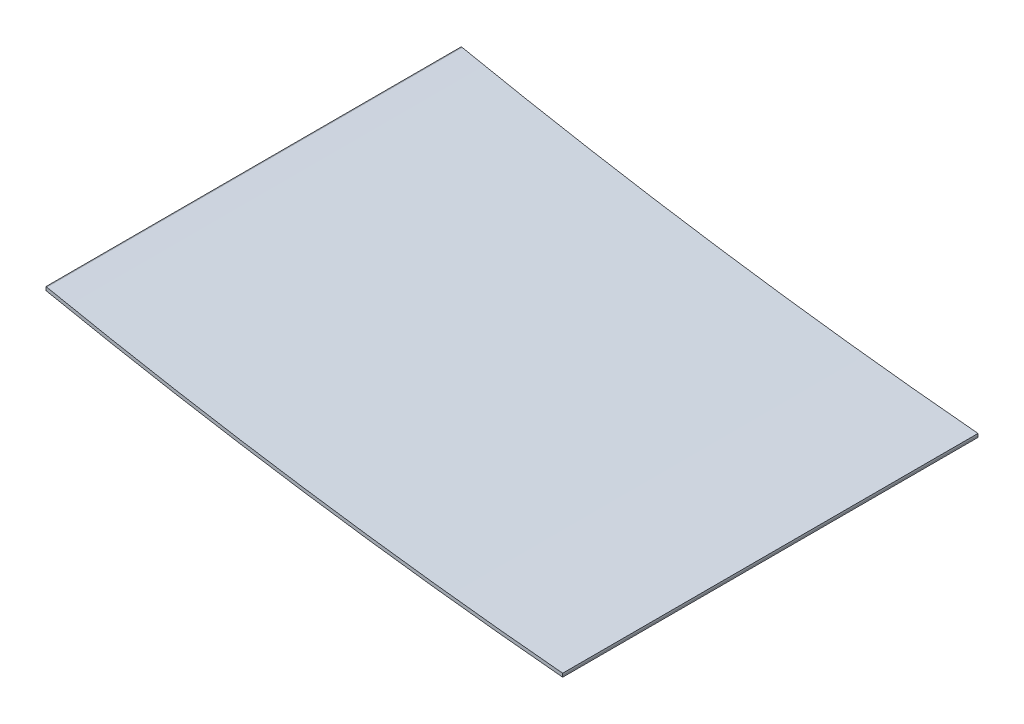
from build123d import *

# Parameters (mm, degrees)
BOSS_EXTRUDE1_DEPTH = 600


with BuildPart() as part:
    # Sketch2 → Boss-Extrude1 (new body)
    with BuildSketch(Plane.XY):
        with BuildLine():
            Line((8671.180248107, -15050.67644099), (8671.180248107, -15047.570291511))
            ThreePointArc((8671.180248107, -15047.570291511), (8296.961694468, -15002.727582577), (7925.803525446, -14937.214164091))
            Line((7925.803525446, -14937.214164091), (7924.798244697, -14937.007753794))
            Line((7924.798244697, -14937.007753794), (7924.798244697, -14942.112062683))
            ThreePointArc((7924.798244697, -14942.112062683), (8296.455606532, -15007.707153296), (8671.178621007, -15052.591147568))
            Line((8671.178621007, -15052.591147568), (8671.180248107, -15050.67644099))
        make_face()
    extrude(amount=BOSS_EXTRUDE1_DEPTH)


solid = part.part
